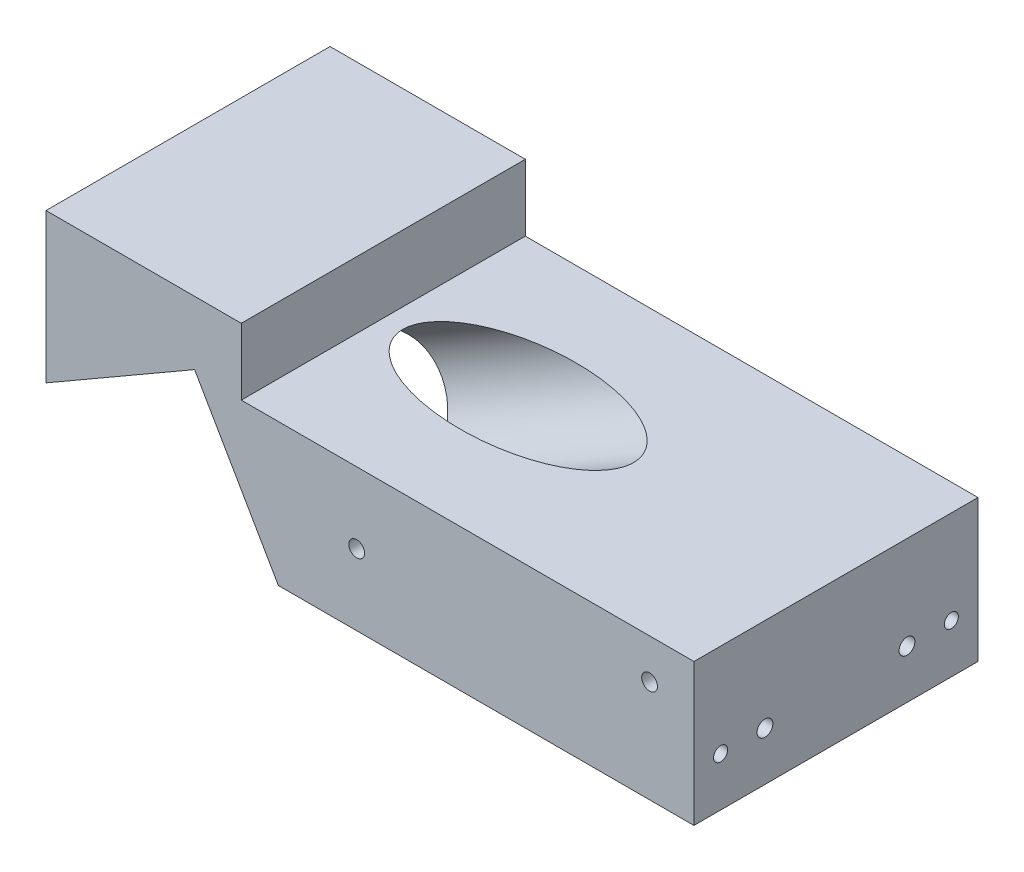
from build123d import *

# Parameters (mm, degrees)
SKETCH1_W                       = 73
SKETCH1_H                       = 32
BOSS_EXTRUDE1_DEPTH             = 16
SKETCH78_W                      = 22
SKETCH78_H                      = 7.5
BOSS_EXTRUDE4_DEPTH             = 32
CUT_EXTRUDE23_DEPTH             = 41
SKETCH14_R                      = 6.5
CUT_EXTRUDE2_DEPTH              = 41
CUT_EXTRUDE2_DEPTH_BACK         = 33
F_2_56_TAPPED_HOLE1_D           = 1.778
F_2_56_TAPPED_HOLE1_DEPTH       = 6.35
F_2_56_TAPPED_HOLE1_TIP         = 0.53416509
F_2_56_TAPPED_HOLE2_D           = 1.778
F_2_56_TAPPED_HOLE2_DEPTH       = 6.35
F_2_56_TAPPED_HOLE2_TIP         = 0.53416509
F_2_56_TAPPED_HOLE3_D           = 1.778
F_2_56_TAPPED_HOLE3_DEPTH       = 6.35
F_2_56_TAPPED_HOLE3_TIP         = 0.53416509
F_2_56_TAPPED_HOLE4_D           = 1.778
F_2_56_TAPPED_HOLE4_DEPTH       = 6.35
F_2_56_TAPPED_HOLE4_TIP         = 0.53416509
F_2_56_TAPPED_HOLE5_D           = 1.778
F_2_56_TAPPED_HOLE5_DEPTH       = 4.76
F_2_56_TAPPED_HOLE5_TIP         = 0.53416509
F_2_56_TAPPED_HOLE7_D           = 1.778
F_2_56_TAPPED_HOLE7_DEPTH       = 15
F_2_56_TAPPED_HOLE7_TIP         = 0.53416509
F_1_16_0_0625_DOWEL_HOLE1_D     = 1.5875
F_1_16_0_0625_DOWEL_HOLE1_DEPTH = 6.5
F_1_16_0_0625_DOWEL_HOLE1_TIP   = 0.476933116


with BuildPart() as part:
    # Sketch1 → Boss-Extrude1 (new body)
    with BuildSketch(Plane(origin=(0, 0, 0), x_dir=(1, 0, 0), z_dir=(0, 1, 0))):
        Rectangle(SKETCH1_W, SKETCH1_H)
    extrude(amount=BOSS_EXTRUDE1_DEPTH)

    # Sketch78 → Boss-Extrude4 (add)
    with BuildSketch(Plane.XY.offset(16)):
        with Locations((-25.5, 19.75)):
            Rectangle(SKETCH78_W, SKETCH78_H)
    extrude(amount=-BOSS_EXTRUDE4_DEPTH)

    # Sketch79 → Cut-Extrude23 (cut)
    with BuildSketch(Plane(origin=(0, 0, -16), x_dir=(-1, 0, 0), z_dir=(0, 0, -1))):
        Polygon((14.495082625, 7.2325), (19.757582625, 16.347417375), (36.5, 6.681178197), (36.5, 0), (10.319396803, 0), align=None)
    extrude(amount=-CUT_EXTRUDE23_DEPTH, mode=Mode.SUBTRACT)

    # Sketch14 → Cut-Extrude2 (cut, two sides)
    with BuildSketch(Plane(origin=(-13.426065962, 5.380908825, -20), x_dir=(0, 0, 1), z_dir=(-0.866025404, -0.5, 0))) as cut_extrude2_sk:
        with Locations((20, 2.138033327)):
            Circle(SKETCH14_R)
    extrude(amount=CUT_EXTRUDE2_DEPTH, mode=Mode.SUBTRACT)
    extrude(cut_extrude2_sk.sketch, amount=-CUT_EXTRUDE2_DEPTH_BACK, mode=Mode.SUBTRACT)

    # #2-56 Tapped Hole1
    with Locations(Plane.ZY.offset(36.5)):
        with Locations((-10, 14.681178197), (10, 14.681178197)):
            Hole(F_2_56_TAPPED_HOLE1_D / 2, depth=F_2_56_TAPPED_HOLE1_DEPTH)
            with Locations((0, 0, -(F_2_56_TAPPED_HOLE1_DEPTH + F_2_56_TAPPED_HOLE1_TIP / 2))):  # 118° drill point
                Cone(0, F_2_56_TAPPED_HOLE1_D / 2, F_2_56_TAPPED_HOLE1_TIP, mode=Mode.SUBTRACT)

    # #2-56 Tapped Hole2
    with Locations(Plane(origin=(0, 0, -16), x_dir=(-1, 0, 0), z_dir=(0, 0, -1))):
        with Locations((-31.5, 11.5), (1.5, 8)):
            Hole(F_2_56_TAPPED_HOLE2_D / 2, depth=F_2_56_TAPPED_HOLE2_DEPTH)
            with Locations((0, 0, -(F_2_56_TAPPED_HOLE2_DEPTH + F_2_56_TAPPED_HOLE2_TIP / 2))):  # 118° drill point
                Cone(0, F_2_56_TAPPED_HOLE2_D / 2, F_2_56_TAPPED_HOLE2_TIP, mode=Mode.SUBTRACT)

    # #2-56 Tapped Hole3
    with Locations(Plane.XY.offset(16)):
        with Locations((-1.5, 8), (31.5, 11.5)):
            Hole(F_2_56_TAPPED_HOLE3_D / 2, depth=F_2_56_TAPPED_HOLE3_DEPTH)
            with Locations((0, 0, -(F_2_56_TAPPED_HOLE3_DEPTH + F_2_56_TAPPED_HOLE3_TIP / 2))):  # 118° drill point
                Cone(0, F_2_56_TAPPED_HOLE3_D / 2, F_2_56_TAPPED_HOLE3_TIP, mode=Mode.SUBTRACT)

    # #2-56 Tapped Hole4
    with Locations(Plane(origin=(-7.739547602, -4.468429892, 0), x_dir=(0, 0, 1), z_dir=(-0.866025404, -0.5, 0))):
        with Locations((-10, 13.511070046), (10, 13.511070046), (0, 13.511070046)):
            Hole(F_2_56_TAPPED_HOLE4_D / 2, depth=F_2_56_TAPPED_HOLE4_DEPTH)
            with Locations((0, 0, -(F_2_56_TAPPED_HOLE4_DEPTH + F_2_56_TAPPED_HOLE4_TIP / 2))):  # 118° drill point
                Cone(0, F_2_56_TAPPED_HOLE4_D / 2, F_2_56_TAPPED_HOLE4_TIP, mode=Mode.SUBTRACT)

    # #2-56 Tapped Hole5
    with Locations(Plane(origin=(0, 0, -16), x_dir=(-1, 0, 0), z_dir=(0, 0, -1))):
        with Locations((31.5, 19)):
            Hole(F_2_56_TAPPED_HOLE5_D / 2, depth=F_2_56_TAPPED_HOLE5_DEPTH)
            with Locations((0, 0, -(F_2_56_TAPPED_HOLE5_DEPTH + F_2_56_TAPPED_HOLE5_TIP / 2))):  # 118° drill point
                Cone(0, F_2_56_TAPPED_HOLE5_D / 2, F_2_56_TAPPED_HOLE5_TIP, mode=Mode.SUBTRACT)

    # #2-56 Tapped Hole7
    with Locations(Plane(origin=(36.5, 0, 0), x_dir=(0, 0, -1), z_dir=(1, 0, 0))):
        with Locations((-8, 5.5), (8, 5.5)):
            Hole(F_2_56_TAPPED_HOLE7_D / 2, depth=F_2_56_TAPPED_HOLE7_DEPTH)
            with Locations((0, 0, -(F_2_56_TAPPED_HOLE7_DEPTH + F_2_56_TAPPED_HOLE7_TIP / 2))):  # 118° drill point
                Cone(0, F_2_56_TAPPED_HOLE7_D / 2, F_2_56_TAPPED_HOLE7_TIP, mode=Mode.SUBTRACT)

    # 1/16 (0.0625) Dowel Hole1
    with Locations(Plane(origin=(36.5, 0, 0), x_dir=(0, 0, -1), z_dir=(1, 0, 0))):
        with Locations((13, 5.5), (-13, 5.5)):
            Hole(F_1_16_0_0625_DOWEL_HOLE1_D / 2, depth=F_1_16_0_0625_DOWEL_HOLE1_DEPTH)
            with Locations((0, 0, -(F_1_16_0_0625_DOWEL_HOLE1_DEPTH + F_1_16_0_0625_DOWEL_HOLE1_TIP / 2))):  # 118° drill point
                Cone(0, F_1_16_0_0625_DOWEL_HOLE1_D / 2, F_1_16_0_0625_DOWEL_HOLE1_TIP, mode=Mode.SUBTRACT)


solid = part.part
